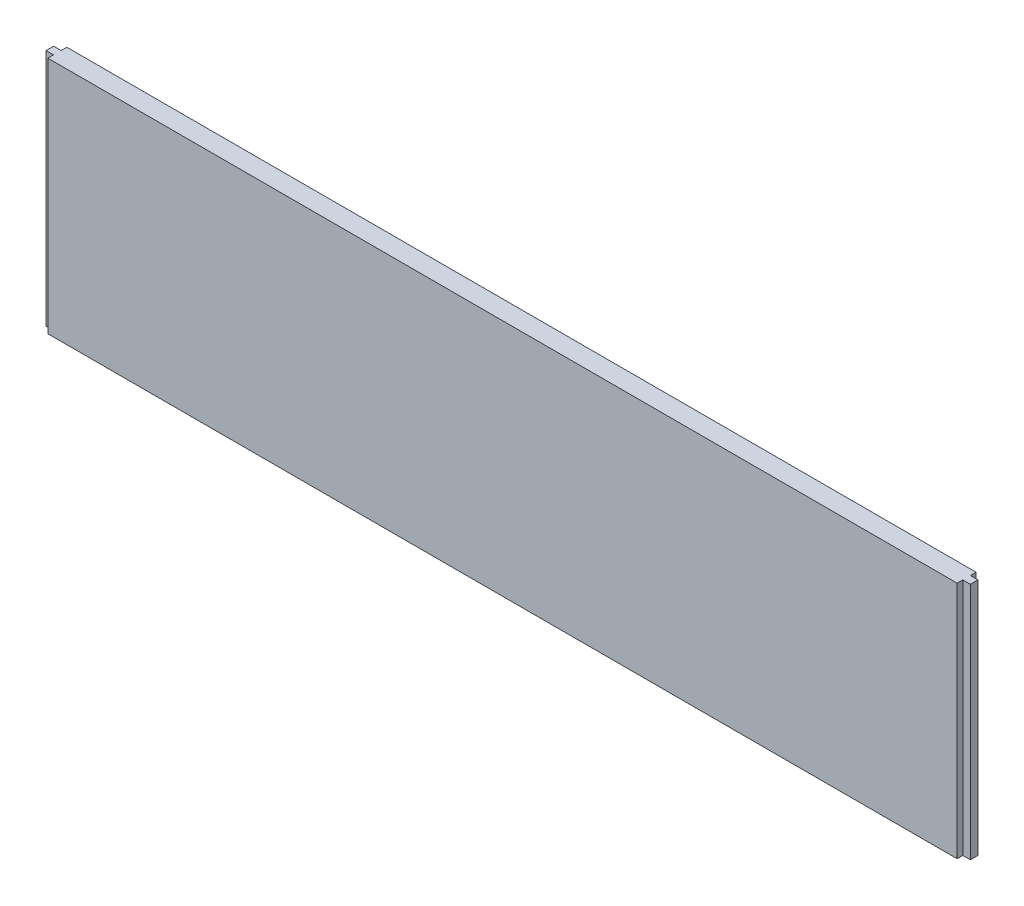
from build123d import *

# Parameters (mm, degrees)
SKETCH1_W           = 774.7
SKETCH1_H           = 200.025
BOSS_EXTRUDE1_DEPTH = 15.875
SKETCH2_W           = 6.35
SKETCH2_H           = 4.7625
CUT_EXTRUDE1_DEPTH  = 201.025


with BuildPart() as part:
    # Sketch1 → Boss-Extrude1 (new body)
    with BuildSketch(Plane.XY):
        with Locations((387.35, 100.0125)):
            Rectangle(SKETCH1_W, SKETCH1_H)
    extrude(amount=BOSS_EXTRUDE1_DEPTH)

    # Sketch2 → Cut-Extrude1 (cut, through all)
    with BuildSketch(Plane(origin=(0, 200.025, 0), x_dir=(1, 0, 0), z_dir=(0, 1, 0))):
        with Locations((771.525, -13.49375)):
            Rectangle(SKETCH2_W, SKETCH2_H)
        with Locations((771.525, -2.38125)):
            Rectangle(SKETCH2_W, SKETCH2_H)
        with Locations((3.175, -2.38125)):
            Rectangle(SKETCH2_W, SKETCH2_H)
        with Locations((3.175, -13.49375)):
            Rectangle(SKETCH2_W, SKETCH2_H)
    extrude(amount=-CUT_EXTRUDE1_DEPTH, mode=Mode.SUBTRACT)


solid = part.part
